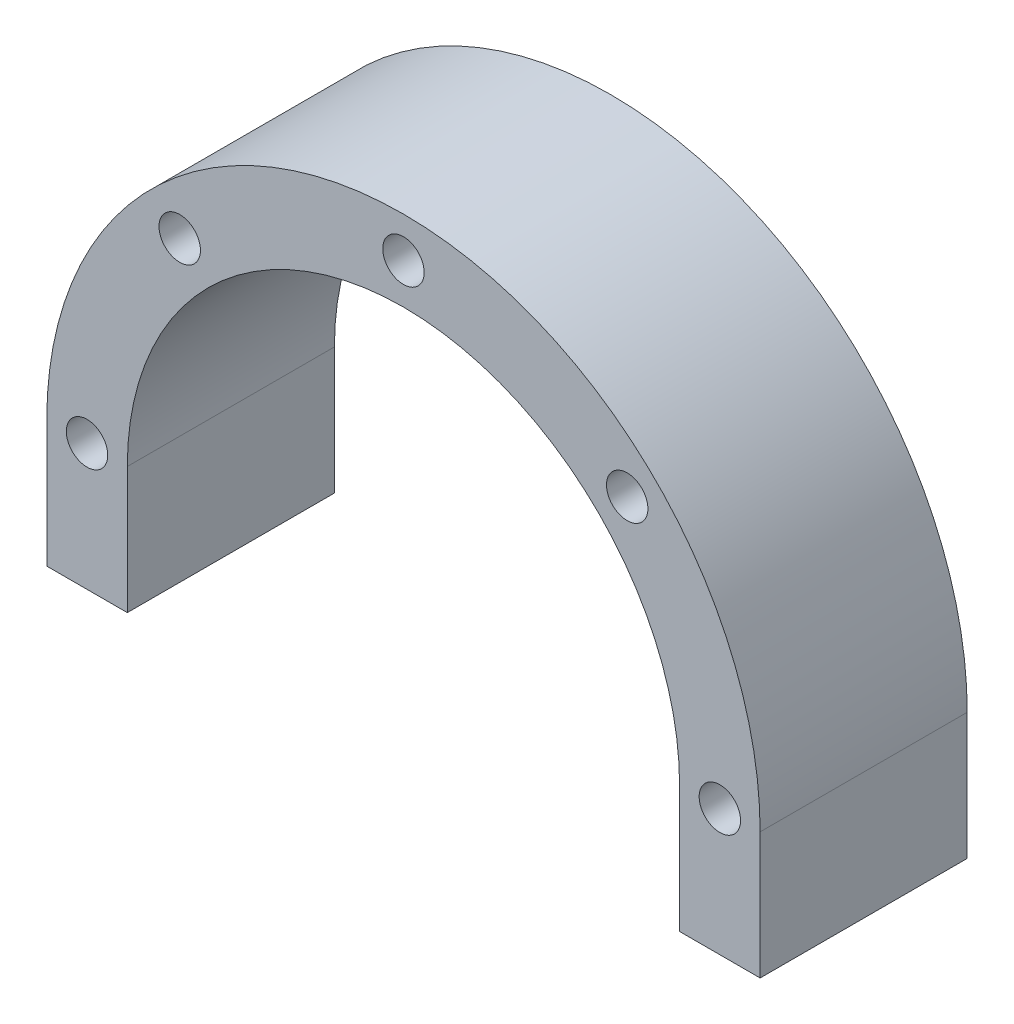
from build123d import *

# Parameters (mm, degrees)
EXTRUDE_1_DEPTH          = 18
CUT_EXTRUDE_1_DEPTH      = 19
HOLE_WIZARD_M3_1_D       = 3.6
PATTERN_CIRCULAR_1_COUNT = 8


with BuildPart() as part:
    # ｽｹｯﾁ1 → ﾎﾞｽ - 押し出し1 (new body)
    with BuildSketch(Plane.XY):
        with BuildLine():
            ThreePointArc((-31, 0), (0, 31), (31, 0))
            Line((31, 0), (31, -11))
            Line((31, -11), (-31, -11))
            Line((-31, -11), (-31, 0))
        make_face()
    extrude(amount=EXTRUDE_1_DEPTH)

    # ｽｹｯﾁ2 → ｶｯﾄ - 押し出し1 (cut, through all)
    with BuildSketch(Plane.XY.offset(18)):
        with BuildLine():
            Line((-24, 0), (-24, -11))
            Line((-24, -11), (24, -11))
            Line((24, -11), (24, 0))
            ThreePointArc((24, 0), (0, 24), (-24, 0))
        make_face()
    extrude(amount=-CUT_EXTRUDE_1_DEPTH, mode=Mode.SUBTRACT)

    # M3 すきま穴1 (through all)
    with Locations(Plane.XY.offset(18)):
        with Locations((0, 27.5)):
            hole_wizard_m3_1 = Hole(HOLE_WIZARD_M3_1_D / 2)

    # 円形ﾊﾟﾀｰﾝ1: M3 すきま穴1 ×8 about axis, 3 skipped
    pattern_circular_1_axis = Axis((0, 0, 0), (0, 0, -1))
    add([hole_wizard_m3_1.rotate(pattern_circular_1_axis, i * 360 / PATTERN_CIRCULAR_1_COUNT) for i in range(1, PATTERN_CIRCULAR_1_COUNT) if i not in (3, 4, 5)], mode=Mode.SUBTRACT)


solid = part.part
